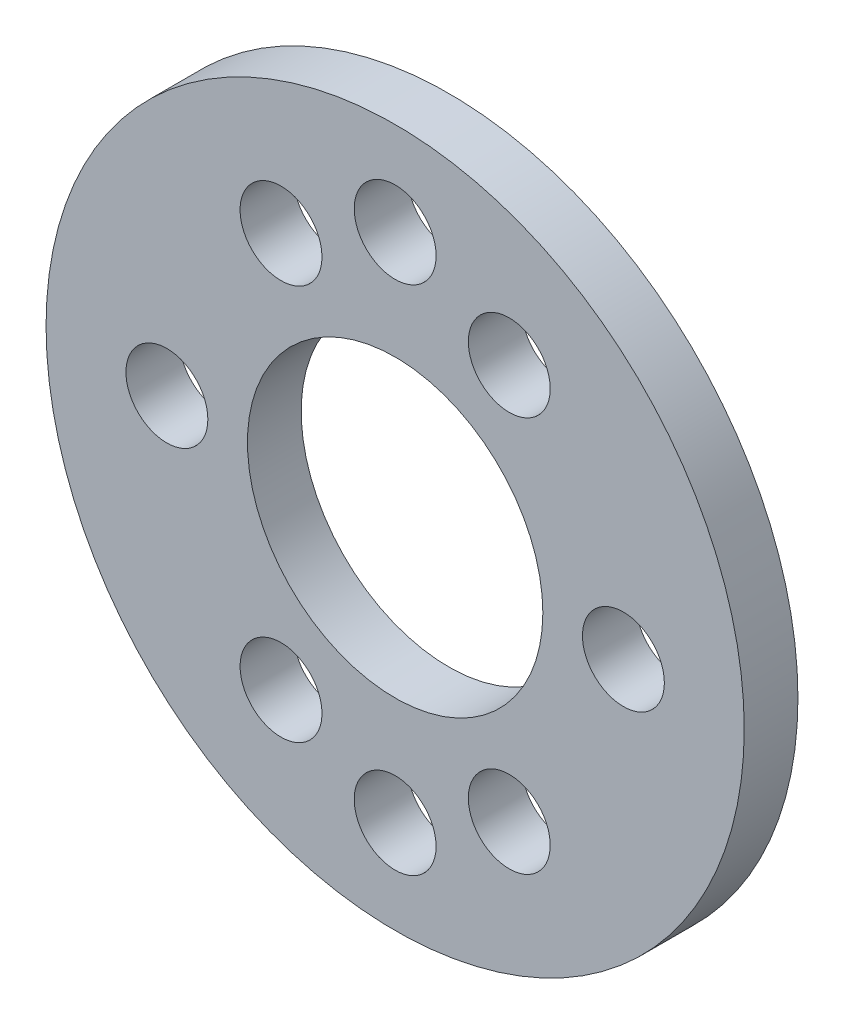
from build123d import *

# Parameters (mm, degrees)
SKETCH2_R           = 13
SKETCH2_R_2         = 5.5
SKETCH2_R_3         = 1.525
BOSS_EXTRUDE1_DEPTH = 2


with BuildPart() as part:
    # Sketch2 → Boss-Extrude1 (new body)
    with BuildSketch(Plane(origin=(0, 0, 0), x_dir=(0, 1, 0), z_dir=(0, 0, 1))):
        Circle(SKETCH2_R)
        Circle(SKETCH2_R_2, mode=Mode.SUBTRACT)
        with Locations((0, 8.5)):
            Circle(SKETCH2_R_3, mode=Mode.SUBTRACT)
        with Locations((0, -8.5)):
            Circle(SKETCH2_R_3, mode=Mode.SUBTRACT)
        with Locations((7.361215932, 4.25)):
            Circle(SKETCH2_R_3, mode=Mode.SUBTRACT)
        with Locations((7.361215932, -4.25)):
            Circle(SKETCH2_R_3, mode=Mode.SUBTRACT)
        with Locations((-7.361215932, -4.25)):
            Circle(SKETCH2_R_3, mode=Mode.SUBTRACT)
        with Locations((-7.361215932, 4.25)):
            Circle(SKETCH2_R_3, mode=Mode.SUBTRACT)
        with Locations((-9.525, 0)):
            Circle(SKETCH2_R_3, mode=Mode.SUBTRACT)
        with Locations((9.525, 0)):
            Circle(SKETCH2_R_3, mode=Mode.SUBTRACT)
    extrude(amount=BOSS_EXTRUDE1_DEPTH)


solid = part.part
